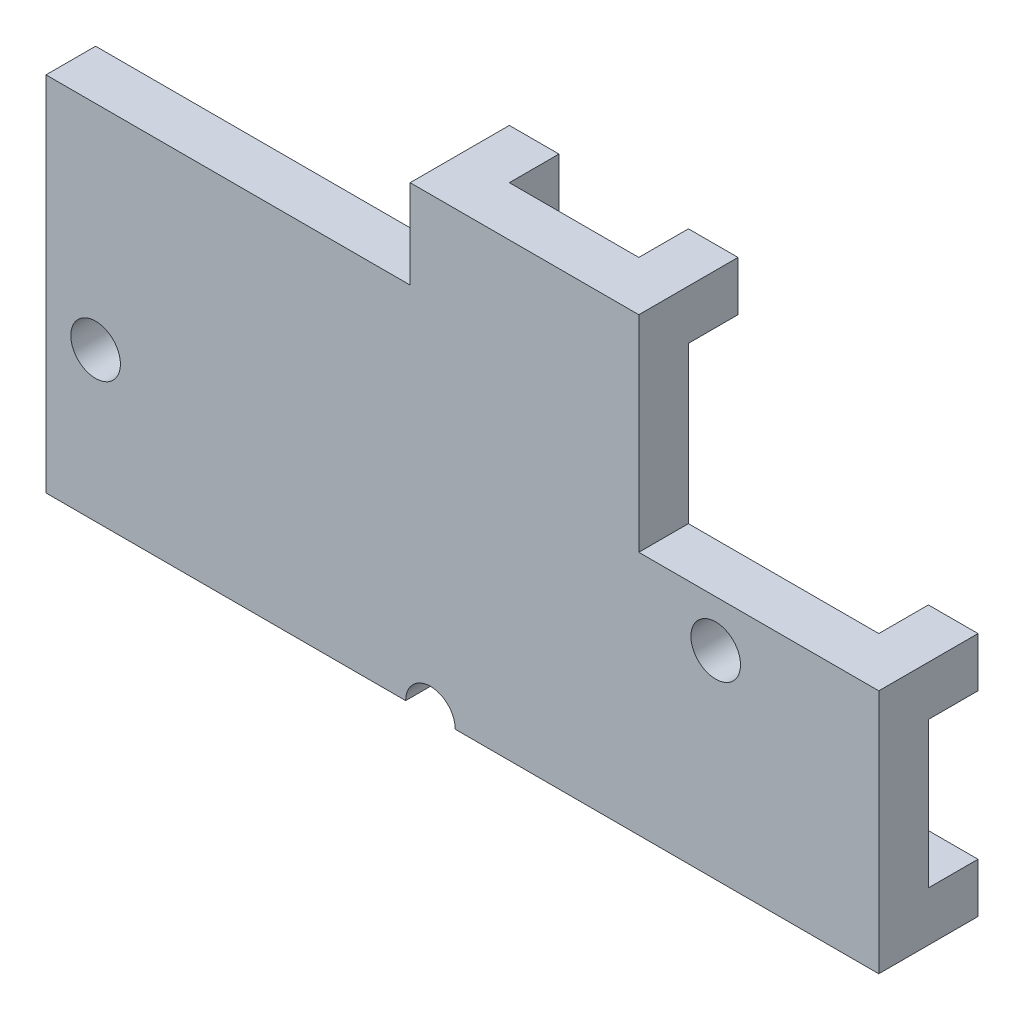
from build123d import *

# Parameters (mm, degrees)
SKETCH1_W            = 15
SKETCH1_H            = 7.3
BOSS_EXTRUDE1_DEPTH  = 1
SKETCH2_W            = 3.05
SKETCH2_H            = 2.36
CUT_EXTRUDE1_DEPTH   = 1
SKETCH5_W            = 1
SKETCH5_H            = 4.94
ENGTH_EXTRUDE_DEPTH  = 1.7874
SKETCH6_W            = 4.61
SKETCH6_H            = 1
HEIGHT_EXTRUDE_DEPTH = 1.7874
SCREWS_R             = 0.5
CUT_EXTRUDE2_DEPTH   = 1
SKETCH8_W            = 1
SKETCH8_H            = 1
PINS_DEPTH           = 1


with BuildPart() as part:
    # Sketch1 → Boss-Extrude1 (new body)
    with BuildSketch(Plane.XY):
        with Locations((88.072707455, -6.376080206)):
            Rectangle(SKETCH1_W, SKETCH1_H)
    extrude(amount=BOSS_EXTRUDE1_DEPTH)

    # Sketch2 → Cut-Extrude1 (cut)
    with BuildSketch(Plane.XY.offset(1)):
        with Locations((94.047707455, -3.906080206)):
            Rectangle(SKETCH2_W, SKETCH2_H)
    extrude(amount=-CUT_EXTRUDE1_DEPTH, mode=Mode.SUBTRACT)

    # Sketch5 → :ength-Extrude (add)
    with BuildSketch(Plane(origin=(95.572707455, 0, 0), x_dir=(0, 0, -1), z_dir=(1, 0, 0))):
        with Locations((-0.5, -7.556080206)):
            Rectangle(SKETCH5_W, SKETCH5_H)
    extrude(amount=ENGTH_EXTRUDE_DEPTH)

    # Sketch6 → Height-Extrude (add)
    with BuildSketch(Plane(origin=(0, -2.726080206, 0), x_dir=(1, 0, 0), z_dir=(0, 1, 0))):
        with Locations((90.217707455, -0.5)):
            Rectangle(SKETCH6_W, SKETCH6_H)
    extrude(amount=HEIGHT_EXTRUDE_DEPTH)

    # Screws → Cut-Extrude2 (cut)
    with BuildSketch(Plane(origin=(0, 0, 0), x_dir=(-1, 0, 0), z_dir=(0, 0, -1))):
        with Locations((-81.572707455, -7.026080206)):
            Circle(SCREWS_R)
        with Locations((-88.322707455, -10.026080206)):
            Circle(SCREWS_R)
        with Locations((-94.072707455, -6.026080206)):
            Circle(SCREWS_R)
    extrude(amount=-CUT_EXTRUDE2_DEPTH, mode=Mode.SUBTRACT)

    # Sketch8 → Pins (add)
    with BuildSketch(Plane(origin=(0, 0, 0), x_dir=(-1, 0, 0), z_dir=(0, 0, -1))):
        with Locations((-92.022707455, -1.438680206)):
            Rectangle(SKETCH8_W, SKETCH8_H)
        with Locations((-88.412707455, -1.438680206)):
            Rectangle(SKETCH8_W, SKETCH8_H)
        with Locations((-96.860107455, -5.586080206)):
            Rectangle(SKETCH8_W, SKETCH8_H)
        with Locations((-96.860107455, -9.526080206)):
            Rectangle(SKETCH8_W, SKETCH8_H)
    extrude(amount=PINS_DEPTH)


solid = part.part
